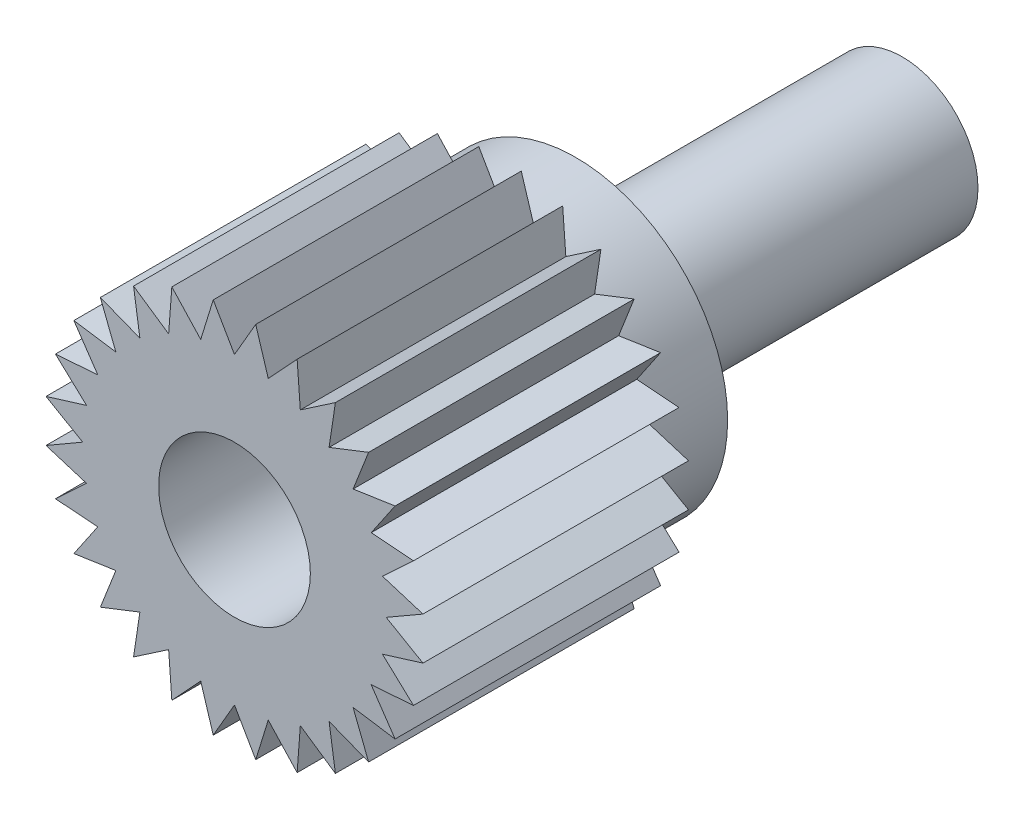
from build123d import *

# Parameters (mm, degrees)
SKETCH_1_R          = 1
EXTRUDE_1_DEPTH     = 4.3
SKETCH_2_R          = 2
EXTRUDE_2_DEPTH     = 1
EXTRUDE_3_DEPTH     = 3.5
SKETCH_4_R          = 1
CUT_EXTRUDE_1_DEPTH = 3


with BuildPart() as part:
    # 草图1 → 凸台-拉伸1 (new body)
    with BuildSketch(Plane.XY):
        Circle(SKETCH_1_R)
    extrude(amount=-EXTRUDE_1_DEPTH)

    # 草图2 → 凸台-拉伸2 (add)
    with BuildSketch(Plane.XY):
        Circle(SKETCH_2_R)
    extrude(amount=EXTRUDE_2_DEPTH)

    # 草图3 → 凸台-拉伸3 (add)
    with BuildSketch(Plane.XY.offset(1)):
        Polygon((2.359708326, -0.825697655), (1.801937736, -0.867767478), (2.116810498, -1.330080191), (1.563662965, -1.246979604), (1.767766953, -1.767766953), (1.246979604, -1.563662965), (1.330080191, -2.116810498), (0.867767478, -1.801937736), (0.825697655, -2.359708326), (0.445041868, -1.949855824), (0.27991119, -2.484280525), (0, -2), (-0.27991119, -2.484280525), (-0.445041868, -1.949855824), (-0.825697655, -2.359708326), (-0.867767478, -1.801937736), (-1.330080191, -2.116810498), (-1.246979604, -1.563662965), (-1.767766953, -1.767766953), (-1.563662965, -1.246979604), (-2.116810498, -1.330080191), (-1.801937736, -0.867767478), (-2.359708326, -0.825697655), (-1.949855824, -0.445041868), (-2.484280525, -0.27991119), (-2, 0), (-2.484280525, 0.27991119), (-1.949855824, 0.445041868), (-2.359708326, 0.825697655), (-1.801937736, 0.867767478), (-2.116810498, 1.330080191), (-1.563662965, 1.246979604), (-1.767766953, 1.767766953), (-1.246979604, 1.563662965), (-1.330080191, 2.116810498), (-0.867767478, 1.801937736), (-0.825697655, 2.359708326), (-0.445041868, 1.949855824), (-0.27991119, 2.484280525), (0, 2), (0.27991119, 2.484280525), (0.445041868, 1.949855824), (0.825697655, 2.359708326), (0.867767478, 1.801937736), (1.330080191, 2.116810498), (1.246979604, 1.563662965), (1.767766953, 1.767766953), (1.563662965, 1.246979604), (2.116810498, 1.330080191), (1.801937736, 0.867767478), (2.359708326, 0.825697655), (1.949855824, 0.445041868), (2.484280525, 0.27991119), (2, 0), (2.484280525, -0.27991119), (1.949855824, -0.445041868), align=None)
    extrude(amount=EXTRUDE_3_DEPTH)

    # 草图4 → 切除-拉伸1 (cut)
    with BuildSketch(Plane.XY.offset(4.5)):
        Circle(SKETCH_4_R)
    extrude(amount=-CUT_EXTRUDE_1_DEPTH, mode=Mode.SUBTRACT)


solid = part.part
